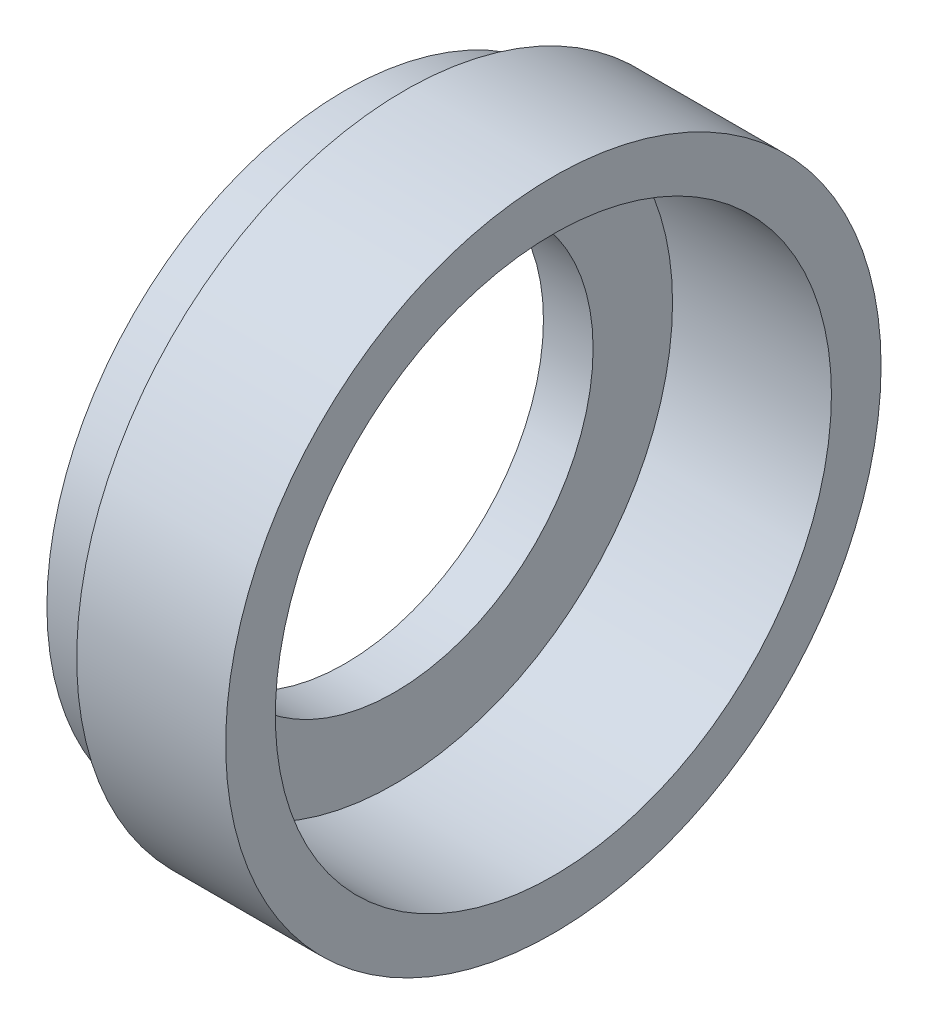
from build123d import *


with BuildPart() as part:
    # Эскиз1 → Повернуть1 (revolve)
    with BuildSketch(Plane.XY):
        Polygon((0, 16.5), (0, 14), (-8, 14), (-8, 10), (-10.5, 10), (-10.5, 15), (-7.5, 15), (-7.5, 16.5), align=None)
    revolve(axis=Axis((0, 0, 0), (-1, 0, 0)))


solid = part.part
